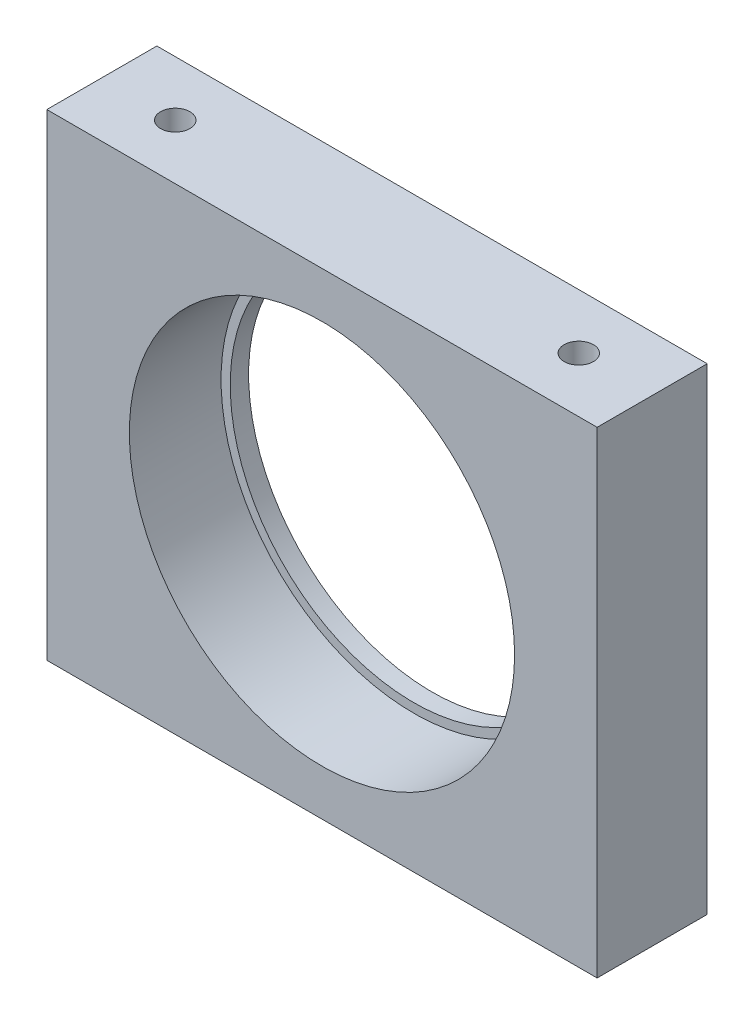
from build123d import *

# Parameters (mm, degrees)
ESQUISSE1_W                                   = 30
ESQUISSE1_H                                   = 26
ESQUISSE1_R                                   = 10
BOSS_EXTRU_1_DEPTH                            = 6
ESQUISSE2_R                                   = 10.5
ENL_V_MAT_EXTRU_1_DEPTH                       = 5
TROU_POUR_TARAUDAGE_POUR_TROU_TARAUD_M2_D     = 1.6
TROU_POUR_TARAUDAGE_POUR_TROU_TARAUD_M2_DEPTH = 10
TROU_POUR_TARAUDAGE_POUR_TROU_TARAUD_M2_TIP   = 0.480688495
TROU_POUR_TARAUDAGE_POUR_TROU_TARAUD_2_D      = 1.6
TROU_POUR_TARAUDAGE_POUR_TROU_TARAUD_2_DEPTH  = 10
TROU_POUR_TARAUDAGE_POUR_TROU_TARAUD_2_TIP    = 0.480688495


with BuildPart() as part:
    # Esquisse1 → Boss.-Extru.1 (new body)
    with BuildSketch(Plane.XY):
        with Locations((15, 13)):
            Rectangle(ESQUISSE1_W, ESQUISSE1_H)
        with Locations((15, 13)):
            Circle(ESQUISSE1_R, mode=Mode.SUBTRACT)
    extrude(amount=BOSS_EXTRU_1_DEPTH)

    # Esquisse2 → Enlèv. mat.-Extru.1 (cut)
    with BuildSketch(Plane.XY.offset(6)):
        with Locations((15, 13)):
            Circle(ESQUISSE2_R)
    extrude(amount=-ENL_V_MAT_EXTRU_1_DEPTH, mode=Mode.SUBTRACT)

    # Trou pour taraudage pour trou taraud_ M2
    with Locations(Plane(origin=(0, 26, 0), x_dir=(1, 0, 0), z_dir=(0, 1, 0))):
        with Locations((4, -3), (26, -3)):
            Hole(TROU_POUR_TARAUDAGE_POUR_TROU_TARAUD_M2_D / 2, depth=TROU_POUR_TARAUDAGE_POUR_TROU_TARAUD_M2_DEPTH)
            with Locations((0, 0, -(TROU_POUR_TARAUDAGE_POUR_TROU_TARAUD_M2_DEPTH + TROU_POUR_TARAUDAGE_POUR_TROU_TARAUD_M2_TIP / 2))):  # 118° drill point
                Cone(0, TROU_POUR_TARAUDAGE_POUR_TROU_TARAUD_M2_D / 2, TROU_POUR_TARAUDAGE_POUR_TROU_TARAUD_M2_TIP, mode=Mode.SUBTRACT)

    # Trou pour taraudage pour trou taraud 2
    with Locations(Plane(origin=(0, 0, 0), x_dir=(-1, 0, 0), z_dir=(0, -1, 0))):
        with Locations((-26, -3), (-4, -3)):
            Hole(TROU_POUR_TARAUDAGE_POUR_TROU_TARAUD_2_D / 2, depth=TROU_POUR_TARAUDAGE_POUR_TROU_TARAUD_2_DEPTH)
            with Locations((0, 0, -(TROU_POUR_TARAUDAGE_POUR_TROU_TARAUD_2_DEPTH + TROU_POUR_TARAUDAGE_POUR_TROU_TARAUD_2_TIP / 2))):  # 118° drill point
                Cone(0, TROU_POUR_TARAUDAGE_POUR_TROU_TARAUD_2_D / 2, TROU_POUR_TARAUDAGE_POUR_TROU_TARAUD_2_TIP, mode=Mode.SUBTRACT)


solid = part.part
